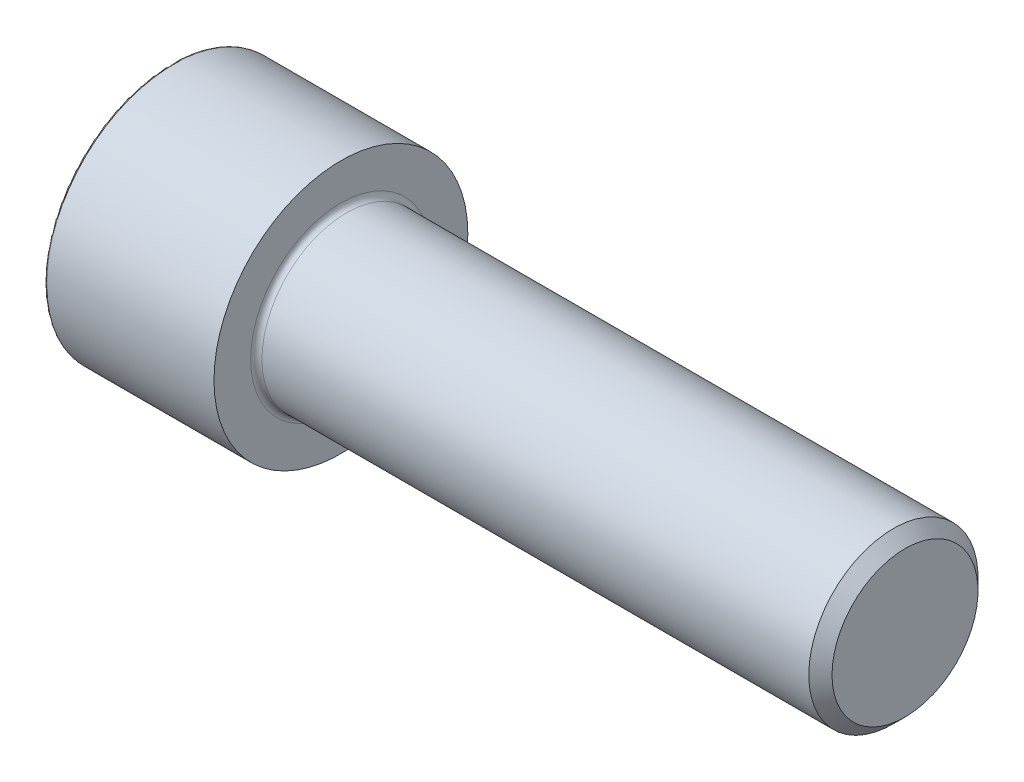
from build123d import *

# Parameters (mm, degrees)
FILLET1_R   = 0.8
FILLET2_R   = 0.3
HEX_2_DEPTH = 12.573


with BuildPart() as part:
    # BodySke → Base-Revolve (revolve)
    with BuildSketch(Plane.XY):
        Polygon((0, 0), (0, 18), (24, 18), (24, 12), (102.352, 12), (104, 10.352), (104, 0), align=None)
    revolve(axis=Axis((-31.75, 0, 0), (1, 0, 0)))

    # Fillet1
    fillet1_edges = [part.edges().sort_by_distance(p)[0] for p in [
        (24, -12, 0),
    ]]
    fillet(fillet1_edges, radius=FILLET1_R)

    # Fillet2
    fillet2_edges = [part.edges().sort_by_distance(p)[0] for p in [
        (0, -18, 0),
    ]]
    fillet(fillet2_edges, radius=FILLET2_R)

    # Sketch2 → Hex-PreBroach (revolve, cut)
    with BuildSketch(Plane.XY):
        Polygon((0, 9.6375), (12.573, 9.6375), (18.137213219, 0), (0, 0), align=None)
    revolve(axis=Axis((0, 0, 0), (1, 0, 0)), mode=Mode.SUBTRACT)

    # Sketch3 → Hex 2 (cut)
    with BuildSketch(Plane(origin=(0, 0, 0), x_dir=(0, 0.5, 0.866025404), z_dir=(-1, 0, 0))):
        Polygon((5.564213219, 9.6375), (-5.564213219, 9.6375), (-11.128426439, 0), (-5.564213219, -9.6375), (5.564213219, -9.6375), (11.128426439, 0), align=None)
    extrude(amount=-HEX_2_DEPTH, mode=Mode.SUBTRACT)


solid = part.part
